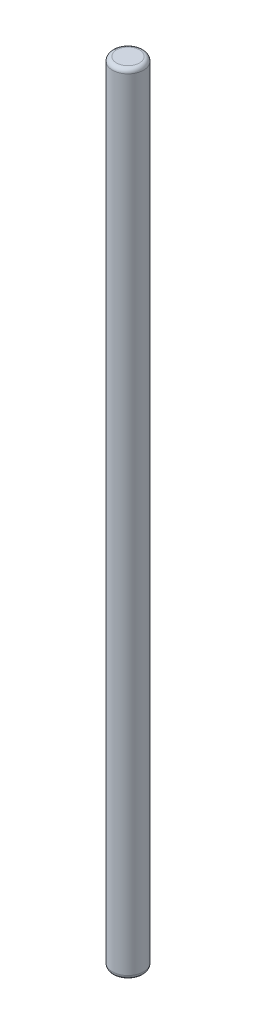
from build123d import *

# Parameters (mm, degrees)
ESQUISSE1_R      = 0.75
EXTRUSION1_DEPTH = 38
CONG_1_R         = 0.2


with BuildPart() as part:
    # Esquisse1 → Extrusion1 (new body)
    with BuildSketch(Plane(origin=(0, 0, 0), x_dir=(1, 0, 0), z_dir=(0, 1, 0))):
        with Locations(Location((0, 0, 0), (0, 0, 270))):  # turned: the seam where the file's is
            Circle(ESQUISSE1_R)
    extrude(amount=EXTRUSION1_DEPTH)

    # Congé1
    cong_1_edges = [part.edges().sort_by_distance(p)[0] for p in [
        (0, 0, -0.75),
        (0, 38, -0.75),
    ]]
    fillet(cong_1_edges, radius=CONG_1_R)


solid = part.part
